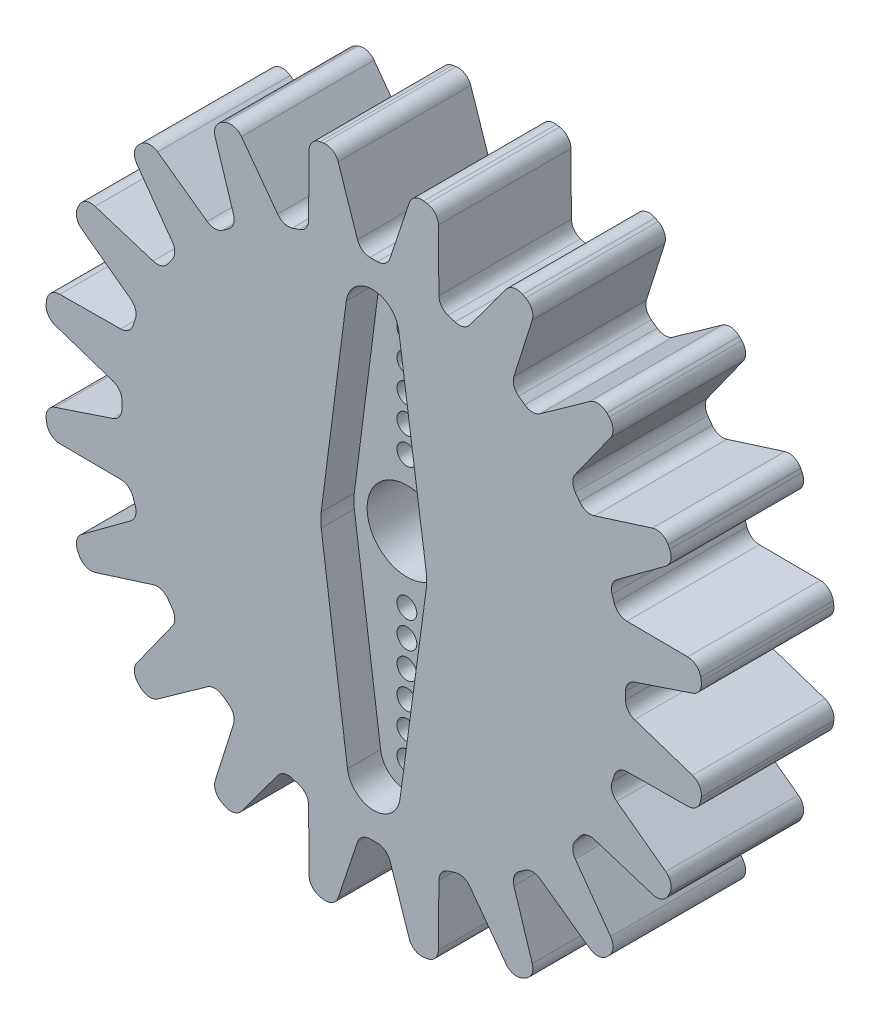
from build123d import *

# Parameters (mm, degrees)
SKETCH1_R                = 25
BOSS_EXTRUDE1_DEPTH      = 10
CUT_EXTRUDE1_START       = -15
CUT_EXTRUDE1_DEPTH       = 15
FILLET2_R                = 1
CIRPATTERN3_COUNT        = 20
FILLET2_OF_CIRPATTERN3_R = 1
CUT_EXTRUDE2_DEPTH       = 2.5
CUT_EXTRUDE3_DEPTH       = 36.760455072
CUT_EXTRUDE3_DEPTH_BACK  = 36.760455072
SKETCH11_R               = 3
SKETCH11_R_2             = 0.75


with BuildPart() as part:
    # Sketch1 → Boss-Extrude1 (new body)
    with BuildSketch(Plane.XY):
        Circle(SKETCH1_R)
    extrude(amount=BOSS_EXTRUDE1_DEPTH)

    # Sketch4 → Cut-Extrude1 (cut)
    with BuildSketch(Plane.XY.offset(10).offset(CUT_EXTRUDE1_START)):
        with BuildLine():
            ThreePointArc((2.94209274, 24.826278221), (0, 25), (-2.94209274, 24.826278221))
            Line((-2.94209274, 24.826278221), (-1, 19))
            Line((-1, 19), (1, 19))
            Line((1, 19), (2.94209274, 24.826278221))
        make_face()
    cut_extrude1 = extrude(amount=CUT_EXTRUDE1_DEPTH, mode=Mode.SUBTRACT)

    # Fillet2
    fillet2_edges = [part.edges().sort_by_distance(p)[0] for p in [
        (1, 19, 5),
        (-1, 19, 5),
        (2.94209274, 24.826278221, 5),
        (-2.94209274, 24.826278221, 5),
    ]]
    fillet(fillet2_edges, radius=FILLET2_R)

    # CirPattern3: Cut-Extrude1 ×20 about axis
    cirpattern3_axis = Axis((0, 0, 10), (0, 0, -1))
    for i in range(1, CIRPATTERN3_COUNT):
        add(cut_extrude1.rotate(cirpattern3_axis, i * 360 / CIRPATTERN3_COUNT), mode=Mode.SUBTRACT)

    # Fillet2 of CirPattern3
    fillet2_of_cirpattern3_edges = [part.edges().sort_by_distance(p)[0] for p in [
        (6.822379409, 17.761056815, 5),
        (4.920266377, 18.379090804, 5),
        (10.46983835, 22.702037022, 5),
        (4.873645405, 24.520350333, 5),
        (11.976936788, 14.783537641, 5),
        (10.358902799, 15.959108145, 5),
        (16.972723234, 18.355562264, 5),
        (12.212317182, 21.814199712, 5),
        (15.959108145, 10.358902799, 5),
        (14.783537641, 11.976936788, 5),
        (21.814199712, 12.212317182, 5),
        (18.355562264, 16.972723234, 5),
        (18.379090804, 4.920266377, 5),
        (17.761056815, 6.822379409, 5),
        (24.520350333, 4.873645405, 5),
        (22.702037022, 10.46983835, 5),
        (19, -1, 5),
        (19, 1, 5),
        (24.826278221, -2.94209274, 5),
        (24.826278221, 2.94209274, 5),
        (17.761056815, -6.822379409, 5),
        (18.379090804, -4.920266377, 5),
        (22.702037022, -10.46983835, 5),
        (24.520350333, -4.873645405, 5),
        (14.783537641, -11.976936788, 5),
        (15.959108145, -10.358902799, 5),
        (18.355562264, -16.972723234, 5),
        (21.814199712, -12.212317182, 5),
        (10.358902799, -15.959108145, 5),
        (11.976936788, -14.783537641, 5),
        (12.212317182, -21.814199712, 5),
        (16.972723234, -18.355562264, 5),
        (4.920266377, -18.379090804, 5),
        (6.822379409, -17.761056815, 5),
        (4.873645405, -24.520350333, 5),
        (10.46983835, -22.702037022, 5),
        (-1, -19, 5),
        (1, -19, 5),
        (-2.94209274, -24.826278221, 5),
        (2.94209274, -24.826278221, 5),
        (-6.822379409, -17.761056815, 5),
        (-4.920266377, -18.379090804, 5),
        (-10.46983835, -22.702037022, 5),
        (-4.873645405, -24.520350333, 5),
        (-11.976936788, -14.783537641, 5),
        (-10.358902799, -15.959108145, 5),
        (-16.972723234, -18.355562264, 5),
        (-12.212317182, -21.814199712, 5),
        (-15.959108145, -10.358902799, 5),
        (-14.783537641, -11.976936788, 5),
        (-21.814199712, -12.212317182, 5),
        (-18.355562264, -16.972723234, 5),
        (-18.379090804, -4.920266377, 5),
        (-17.761056815, -6.822379409, 5),
        (-24.520350333, -4.873645405, 5),
        (-22.702037022, -10.46983835, 5),
        (-19, 1, 5),
        (-19, -1, 5),
        (-24.826278221, 2.94209274, 5),
        (-24.826278221, -2.94209274, 5),
        (-17.761056815, 6.822379409, 5),
        (-18.379090804, 4.920266377, 5),
        (-22.702037022, 10.46983835, 5),
        (-24.520350333, 4.873645405, 5),
        (-14.783537641, 11.976936788, 5),
        (-15.959108145, 10.358902799, 5),
        (-18.355562264, 16.972723234, 5),
        (-21.814199712, 12.212317182, 5),
        (-10.358902799, 15.959108145, 5),
        (-11.976936788, 14.783537641, 5),
        (-12.212317182, 21.814199712, 5),
        (-16.972723234, 18.355562264, 5),
        (-4.920266377, 18.379090804, 5),
        (-6.822379409, 17.761056815, 5),
        (-4.873645405, 24.520350333, 5),
        (-10.46983835, 22.702037022, 5),
    ]]
    fillet(fillet2_of_cirpattern3_edges, radius=FILLET2_OF_CIRPATTERN3_R)

    # Sketch10 → Cut-Extrude2 (cut)
    with BuildSketch(Plane.XY.offset(10)):
        with BuildLine():
            Line((3.961023752, 0.557037552), (1.890784116, 15.278250405))
            ThreePointArc((1.890784116, 15.278250405), (-0.101691462, 16.999695846), (-2.073429957, 15.254536644))
            Line((-2.073429957, 15.254536644), (-3.967404393, 0.50961003))
            ThreePointArc((-3.967404393, 0.50961003), (-3.999982109, -0.011963755), (-3.964284999, -0.533333333))
            Line((-3.964284999, -0.533333333), (-1.9821425, -15.266666667))
            ThreePointArc((-1.9821425, -15.266666667), (0, -17), (1.9821425, -15.266666667))
            Line((1.9821425, -15.266666667), (3.964284999, -0.533333333))
            ThreePointArc((3.964284999, -0.533333333), (3.999982109, 0.011963755), (3.961023752, 0.557037552))
        make_face()
    extrude(amount=-CUT_EXTRUDE2_DEPTH, mode=Mode.SUBTRACT)

    # Sketch11 → Cut-Extrude3 (cut, two sides: drawn at the far end of the back side and taken through both)
    with BuildSketch(Plane.XY.offset(7.5).offset(-CUT_EXTRUDE3_DEPTH_BACK)):
        Circle(SKETCH11_R)
        with Locations((0, 5)):
            Circle(SKETCH11_R_2)
        with Locations((0, -5)):
            Circle(SKETCH11_R_2)
        with Locations((0, 7)):
            Circle(SKETCH11_R_2)
        with Locations((0, 9)):
            Circle(SKETCH11_R_2)
        with Locations((0, 11)):
            Circle(SKETCH11_R_2)
        with Locations((0, 13)):
            Circle(SKETCH11_R_2)
        with Locations((0, 15)):
            Circle(SKETCH11_R_2)
        with Locations((0, -7)):
            Circle(SKETCH11_R_2)
        with Locations((0, -9)):
            Circle(SKETCH11_R_2)
        with Locations((0, -11)):
            Circle(SKETCH11_R_2)
        with Locations((0, -13)):
            Circle(SKETCH11_R_2)
        with Locations((0, -15)):
            Circle(SKETCH11_R_2)
    extrude(amount=CUT_EXTRUDE3_DEPTH + CUT_EXTRUDE3_DEPTH_BACK, mode=Mode.SUBTRACT)


solid = part.part
